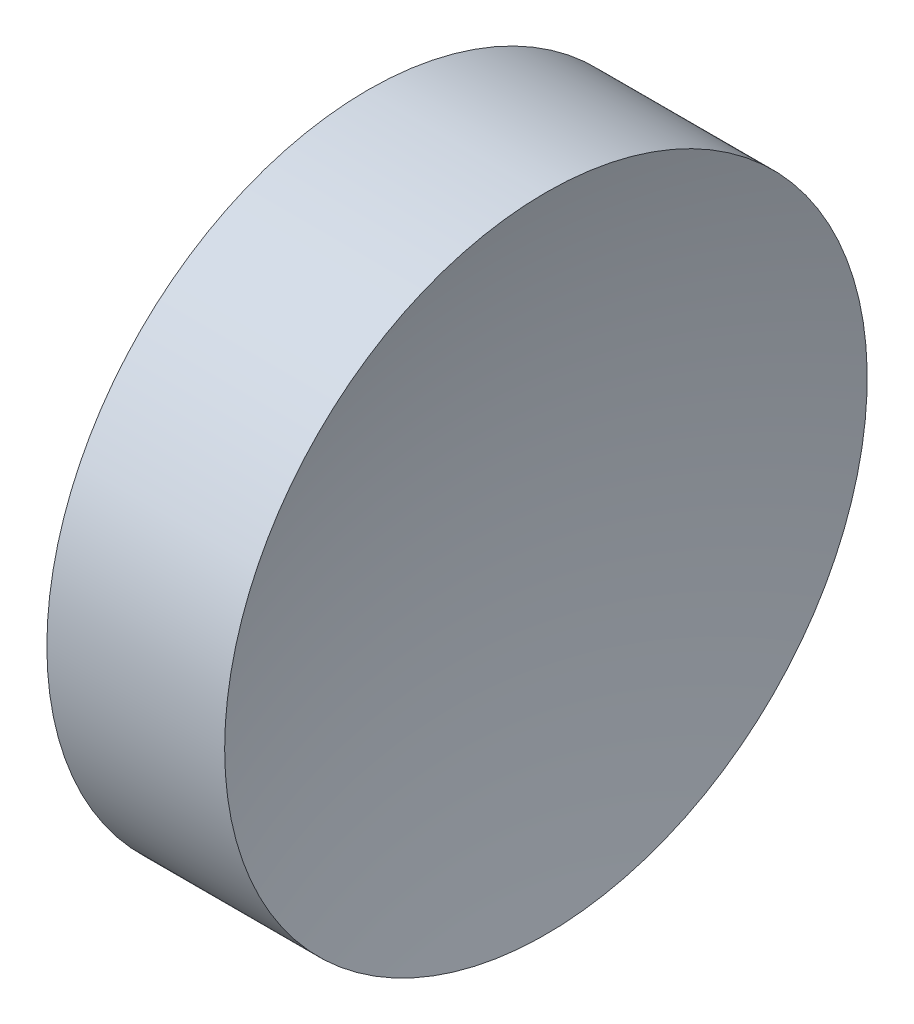
from build123d import *


with BuildPart() as part:
    # 草图1 → 旋转1 (revolve)
    with BuildSketch(Plane.XY):
        with BuildLine():
            Line((121.852703446, 65.222602873), (118.352703446, 65.222602873))
            ThreePointArc((118.352703446, 65.222602873), (117.909605493, 71.63356173), (116.588738061, 77.922602873))
            Line((116.588738061, 77.922602873), (120.102703446, 77.922602873))
            Line((120.102703446, 77.922602873), (123.616668831, 77.922602873))
            ThreePointArc((123.616668831, 77.922602873), (122.2958014, 71.63356173), (121.852703446, 65.222602873))
        make_face()
    revolve(axis=Axis((109.936935226, 65.222602873, 0), (1, 0, 0)))


solid = part.part
